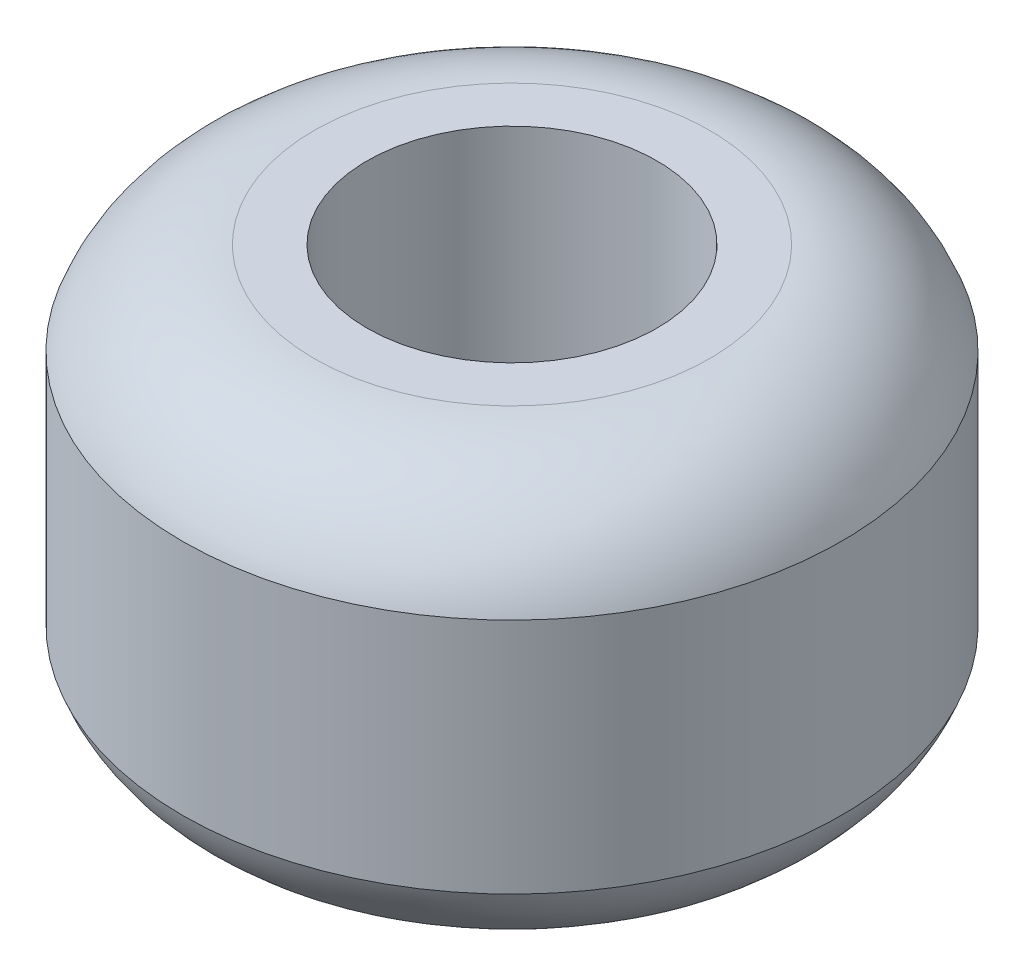
from build123d import *


with BuildPart() as part:
    # Sketch1 → Revolve1 (revolve)
    with BuildSketch(Plane.XY):
        with BuildLine():
            Line((11, 16), (11, -16))
            Line((11, -16), (15, -16))
            ThreePointArc((15, -16), (21.103277808, -14.076111154), (25, -9))
            Line((25, -9), (25, 9))
            ThreePointArc((25, 9), (21.103277808, 14.076111154), (15, 16))
            Line((15, 16), (11, 16))
        make_face()
    revolve(axis=Axis((0, 0, 0), (0, -1, 0)))


solid = part.part
